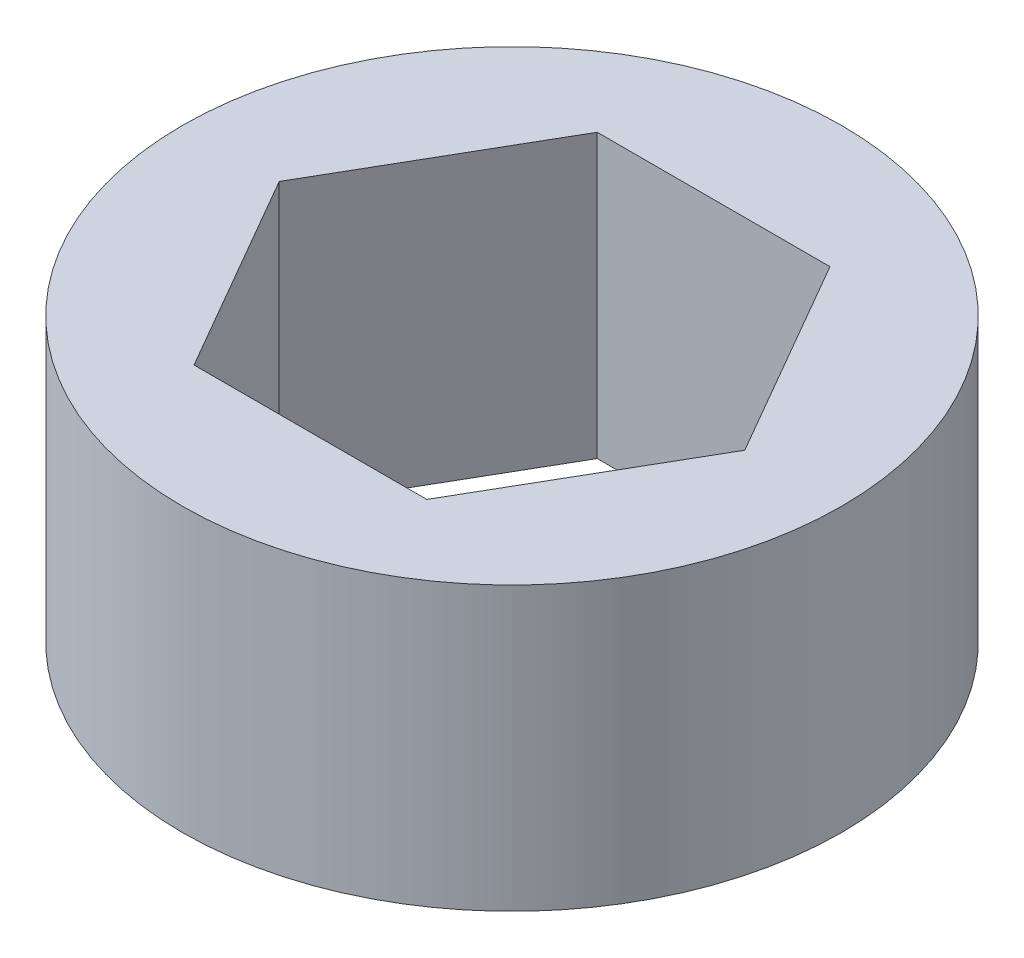
from build123d import *

# Parameters (mm, degrees)
SKETCH1_R           = 11.1125
BOSS_EXTRUDE1_DEPTH = 9.525


with BuildPart() as part:
    # Sketch1 → Boss-Extrude1 (new body)
    with BuildSketch(Plane(origin=(0, 0, 0), x_dir=(1, 0, 0), z_dir=(0, 1, 0))):
        Circle(SKETCH1_R)
        Polygon((7.845612808, 0), (3.922806404, 6.7945), (-3.922806404, 6.7945), (-7.845612808, 0), (-3.922806404, -6.7945), (3.922806404, -6.7945), align=None, mode=Mode.SUBTRACT)
    extrude(amount=BOSS_EXTRUDE1_DEPTH)


solid = part.part
